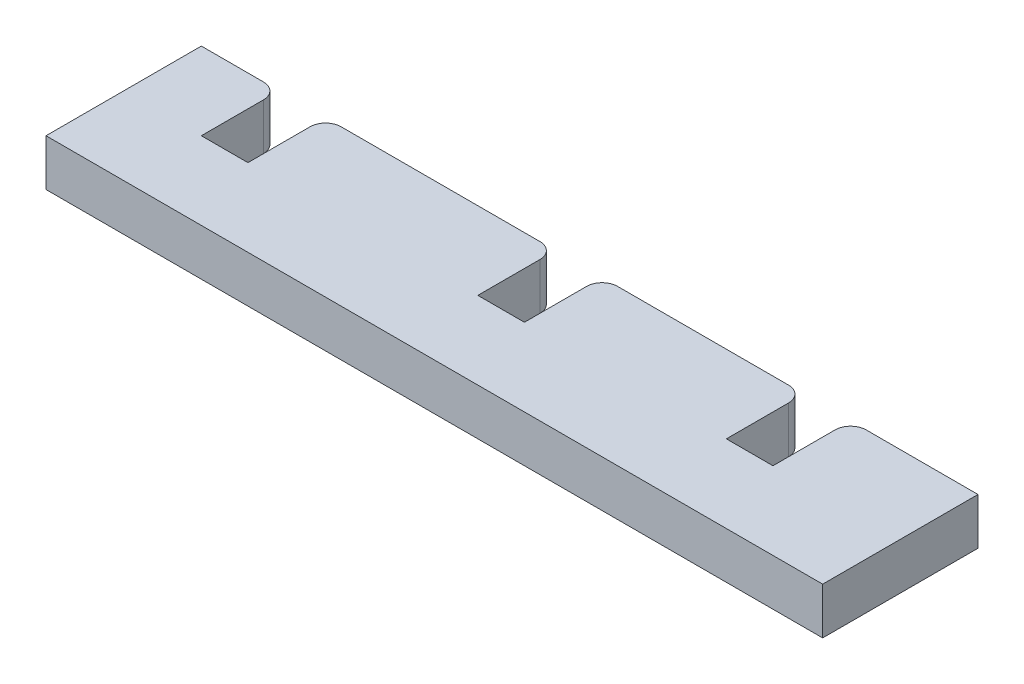
from build123d import *

# Parameters (mm, degrees)
SKETCH1_W           = 50
SKETCH1_H           = 3
BOSS_EXTRUDE1_DEPTH = 10
SKETCH3_W           = 3
SKETCH3_H           = 3
CUT_EXTRUDE2_DEPTH  = 5
FILLET2_R           = 1


with BuildPart() as part:
    # Sketch1 → Boss-Extrude1 (new body)
    with BuildSketch(Plane.XY):
        with Locations((25, 1.5)):
            Rectangle(SKETCH1_W, SKETCH1_H)
    extrude(amount=BOSS_EXTRUDE1_DEPTH)

    # Sketch3 → Cut-Extrude2 (cut)
    with BuildSketch(Plane(origin=(0, 0, 0), x_dir=(-1, 0, 0), z_dir=(0, 0, -1))):
        with Locations((-81.3, 1.5)):
            Rectangle(SKETCH3_W, SKETCH3_H)
        with Locations((-60.3, 1.5)):
            Rectangle(SKETCH3_W, SKETCH3_H)
        with Locations((-40.3, 1.5)):
            Rectangle(SKETCH3_W, SKETCH3_H)
        with Locations((-24.3, 1.5)):
            Rectangle(SKETCH3_W, SKETCH3_H)
        with Locations((-6.5, 1.5)):
            Rectangle(SKETCH3_W, SKETCH3_H)
    extrude(amount=-CUT_EXTRUDE2_DEPTH, mode=Mode.SUBTRACT)

    # Fillet2
    fillet2_edges = [part.edges().sort_by_distance(p)[0] for p in [
        (38.8, 1.5, 0),
        (41.8, 1.5, 0),
        (22.8, 1.5, 0),
        (25.8, 1.5, 0),
        (5, 1.5, 0),
        (8, 1.5, 0),
    ]]
    fillet(fillet2_edges, radius=FILLET2_R)


solid = part.part
